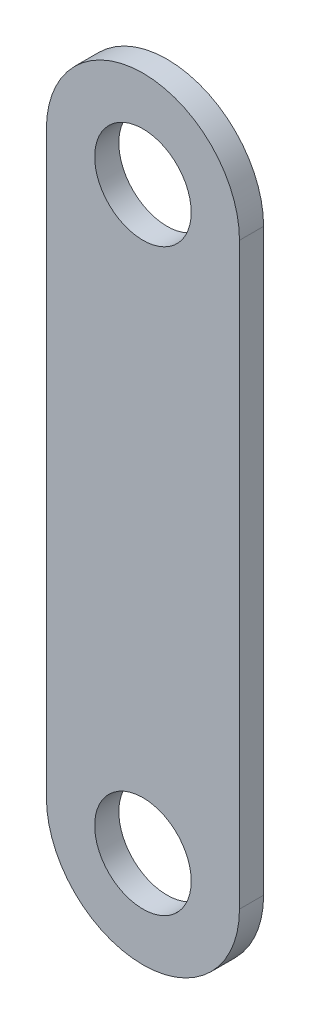
from build123d import *

# Parameters (mm, degrees)
SKETCH1_R           = 6.35
BOSS_EXTRUDE1_DEPTH = 3.175


with BuildPart() as part:
    # Sketch1 → Boss-Extrude1 (new body)
    with BuildSketch(Plane.XY):
        with BuildLine():
            ThreePointArc((1.665901342, 33.129620882), (-11.034098658, 45.829620882), (-23.734098658, 33.129620882))
            Line((-23.734098658, 33.129620882), (-23.734098658, -43.070379118))
            ThreePointArc((-23.734098658, -43.070379118), (-11.034098658, -55.770379118), (1.665901342, -43.070379118))
            Line((1.665901342, -43.070379118), (1.665901342, 33.129620882))
        make_face()
        with Locations((-11.034098658, 33.129620882)):
            Circle(SKETCH1_R, mode=Mode.SUBTRACT)
        with Locations((-11.034098658, -43.070379118)):
            Circle(SKETCH1_R, mode=Mode.SUBTRACT)
    extrude(amount=BOSS_EXTRUDE1_DEPTH)


solid = part.part
